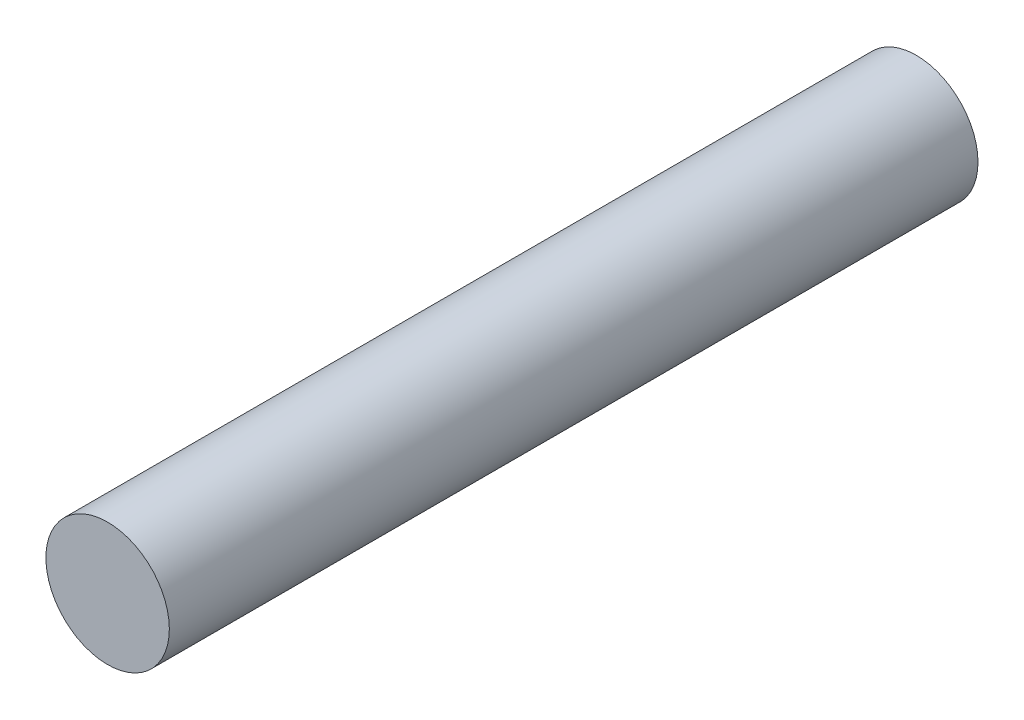
from build123d import *

# Parameters (mm, degrees)
CROQUIS1_R              = 10
SALIENTE_EXTRUIR1_DEPTH = 131


with BuildPart() as part:
    # Croquis1 → Saliente-Extruir1 (new body)
    with BuildSketch(Plane.XY):
        Circle(CROQUIS1_R)
    extrude(amount=SALIENTE_EXTRUIR1_DEPTH)


solid = part.part
